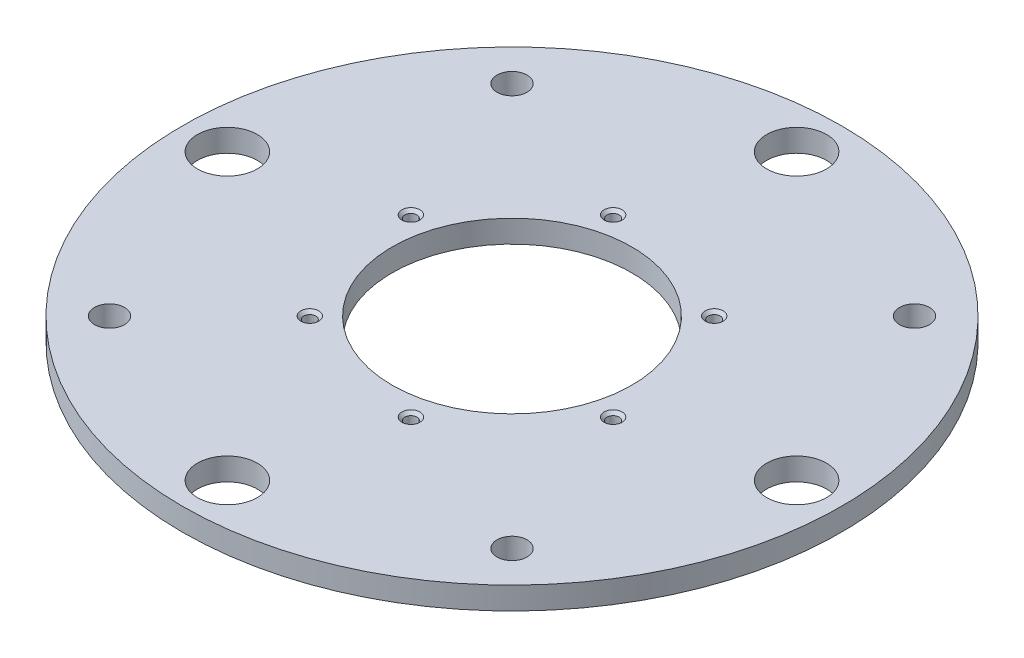
from build123d import *

# Parameters (mm, degrees)
SKETCH2_R                        = 139.7
SKETCH2_R_2                      = 50.8
BOSS_EXTRUDE1_DEPTH              = 9.525
SKETCH3_R                        = 12.6746
SKETCH3_R_2                      = 6.35
CUT_EXTRUDE2_DEPTH               = 10.525
F_1_4_20_TAPPED_HOLE1_AT_2_COUNT = 2
F_1_4_20_TAPPED_HOLE1_AT_2_PITCH = 60.61075
F_1_4_20_TAPPED_HOLE1_AT_3_COUNT = 2
F_1_4_20_TAPPED_HOLE1_AT_3_PITCH = 104.980898485
F_1_4_20_TAPPED_HOLE1_AT_4_COUNT = 2
F_1_4_20_TAPPED_HOLE1_AT_4_PITCH = 121.2215
F_1_4_20_TAPPED_HOLE1_AT_5_COUNT = 2
F_1_4_20_TAPPED_HOLE1_AT_5_PITCH = 104.980898485
F_1_4_20_TAPPED_HOLE1_AT_6_COUNT = 2
F_1_4_20_TAPPED_HOLE1_AT_6_PITCH = 60.61075


with BuildPart() as part:
    # Sketch2 → Boss-Extrude1 (new body)
    with BuildSketch(Plane(origin=(0, 0, 0), x_dir=(1, 0, 0), z_dir=(0, 1, 0))):
        Circle(SKETCH2_R)
        Circle(SKETCH2_R_2, mode=Mode.SUBTRACT)
    extrude(amount=BOSS_EXTRUDE1_DEPTH)

    # Sketch3 → Cut-Extrude2 (cut, through all)
    with BuildSketch(Plane(origin=(0, 9.525, 0), x_dir=(1, 0, 0), z_dir=(0, 1, 0))):
        with Locations((0, 120.65)):
            Circle(SKETCH3_R)
        with Locations((120.65, 0)):
            Circle(SKETCH3_R)
        with Locations((0, -120.65)):
            Circle(SKETCH3_R)
        with Locations((-120.65, 0)):
            Circle(SKETCH3_R)
        with Locations((85.31243315, 85.31243315)):
            Circle(SKETCH3_R_2)
        with Locations((85.31243315, -85.31243315)):
            Circle(SKETCH3_R_2)
        with Locations((-85.31243315, -85.31243315)):
            Circle(SKETCH3_R_2)
        with Locations((-85.31243315, 85.31243315)):
            Circle(SKETCH3_R_2)
    extrude(amount=-CUT_EXTRUDE2_DEPTH, mode=Mode.SUBTRACT)

    # Sketch6 → 1/4-20 Tapped Hole1 (revolve, cut)
    with BuildSketch(Plane(origin=(-58.545488776, 9.525, -15.687216438), x_dir=(0, 0, 1), z_dir=(1, 0, 0))):
        Polygon((0, 0), (0, 9.525), (3.81, 9.525), (2.5527, 8.2677), (2.5527, 1.2573), (3.81, 0), align=None)
    f_1_4_20_tapped_hole1 = revolve(axis=Axis((-58.545488776, 15.875, -15.687216438), (0, -1, 0)), mode=Mode.SUBTRACT)

    # 1/4-20 Tapped Hole1 at 2: 1/4-20 Tapped Hole1 ×2
    with Locations(*[Vector(0.707106781, 0, -0.707106781) * (i * F_1_4_20_TAPPED_HOLE1_AT_2_PITCH) for i in range(1, F_1_4_20_TAPPED_HOLE1_AT_2_COUNT)]):
        add(f_1_4_20_tapped_hole1, mode=Mode.SUBTRACT)

    # 1/4-20 Tapped Hole1 at 3: 1/4-20 Tapped Hole1 ×2
    with Locations(*[Vector(0.965925826, 0, -0.258819045) * (i * F_1_4_20_TAPPED_HOLE1_AT_3_PITCH) for i in range(1, F_1_4_20_TAPPED_HOLE1_AT_3_COUNT)]):
        add(f_1_4_20_tapped_hole1, mode=Mode.SUBTRACT)

    # 1/4-20 Tapped Hole1 at 4: 1/4-20 Tapped Hole1 ×2
    with Locations(*[Vector(0.965925826, 0, 0.258819045) * (i * F_1_4_20_TAPPED_HOLE1_AT_4_PITCH) for i in range(1, F_1_4_20_TAPPED_HOLE1_AT_4_COUNT)]):
        add(f_1_4_20_tapped_hole1, mode=Mode.SUBTRACT)

    # 1/4-20 Tapped Hole1 at 5: 1/4-20 Tapped Hole1 ×2
    with Locations(*[Vector(0.707106781, 0, 0.707106781) * (i * F_1_4_20_TAPPED_HOLE1_AT_5_PITCH) for i in range(1, F_1_4_20_TAPPED_HOLE1_AT_5_COUNT)]):
        add(f_1_4_20_tapped_hole1, mode=Mode.SUBTRACT)

    # 1/4-20 Tapped Hole1 at 6: 1/4-20 Tapped Hole1 ×2
    with Locations(*[Vector(0.258819045, 0, 0.965925826) * (i * F_1_4_20_TAPPED_HOLE1_AT_6_PITCH) for i in range(1, F_1_4_20_TAPPED_HOLE1_AT_6_COUNT)]):
        add(f_1_4_20_tapped_hole1, mode=Mode.SUBTRACT)


solid = part.part
